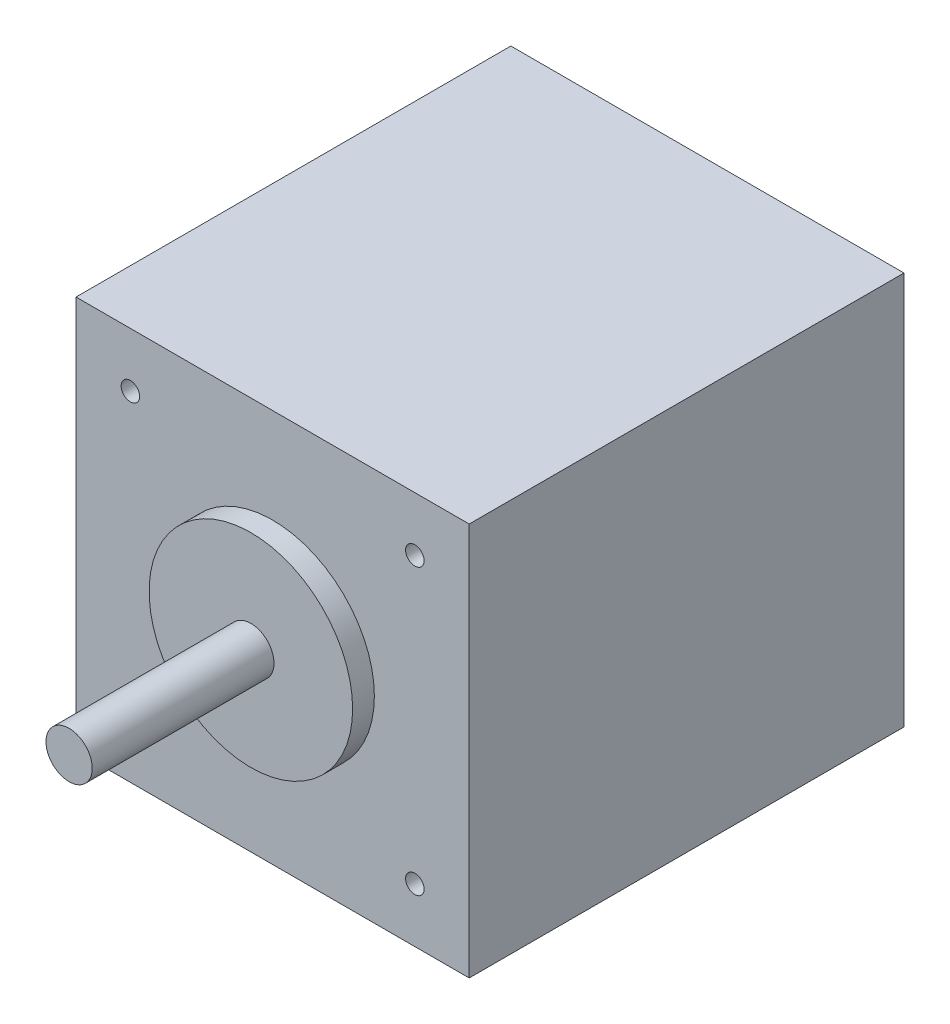
from build123d import *

# Parameters (mm, degrees)
SKETCH1_W           = 42.5
SKETCH1_H           = 42.5
BOSS_EXTRUDE1_DEPTH = 47
SKETCH2_R           = 1
CUT_EXTRUDE1_DEPTH  = 2
SKETCH3_R           = 2.5
BOSS_EXTRUDE2_DEPTH = 22
SKETCH4_R           = 11
BOSS_EXTRUDE3_DEPTH = 2.35


with BuildPart() as part:
    # Sketch1 → Boss-Extrude1 (new body)
    with BuildSketch(Plane.XY):
        Rectangle(SKETCH1_W, SKETCH1_H)
    extrude(amount=BOSS_EXTRUDE1_DEPTH)

    # Sketch2 → Cut-Extrude1 (cut)
    with BuildSketch(Plane.XY.offset(47)):
        with Locations((-15.375, 15.375)):
            Circle(SKETCH2_R)
        with Locations((15.375, 15.375)):
            Circle(SKETCH2_R)
        with Locations((15.375, -15.375)):
            Circle(SKETCH2_R)
        with Locations((-15.375, -15.375)):
            Circle(SKETCH2_R)
    extrude(amount=-CUT_EXTRUDE1_DEPTH, mode=Mode.SUBTRACT)

    # Sketch3 → Boss-Extrude2 (add)
    with BuildSketch(Plane.XY.offset(47)):
        Circle(SKETCH3_R)
    extrude(amount=BOSS_EXTRUDE2_DEPTH)

    # Sketch4 → Boss-Extrude3 (add)
    with BuildSketch(Plane.XY.offset(47)):
        Circle(SKETCH4_R)
    extrude(amount=BOSS_EXTRUDE3_DEPTH)


solid = part.part
